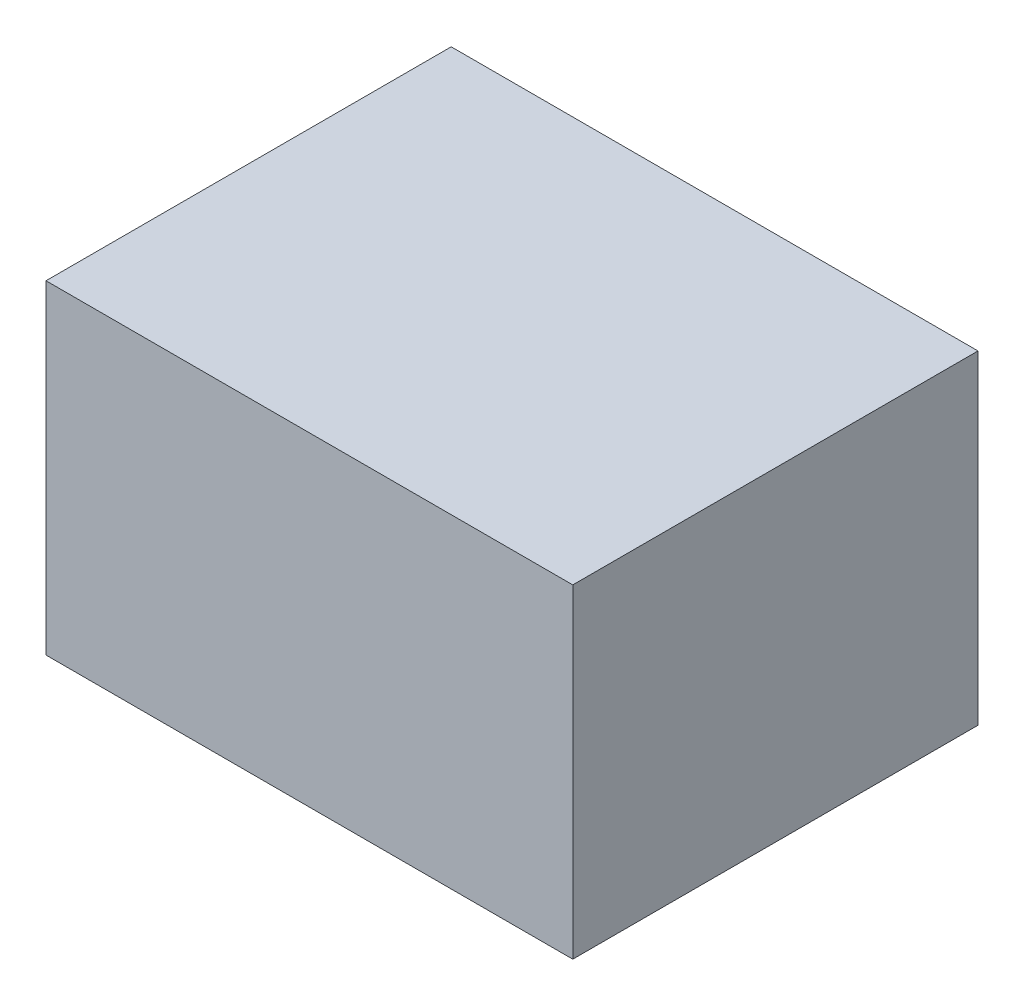
from build123d import *

# Parameters (mm, degrees)
ESQUISSE1_W        = 65
ESQUISSE1_H        = 40
BOSS_EXTRU_1_DEPTH = 50


with BuildPart() as part:
    # Esquisse1 → Boss.-Extru.1 (new body)
    with BuildSketch(Plane.XY):
        with Locations((32.5, -20)):
            Rectangle(ESQUISSE1_W, ESQUISSE1_H)
    extrude(amount=BOSS_EXTRU_1_DEPTH)


solid = part.part
